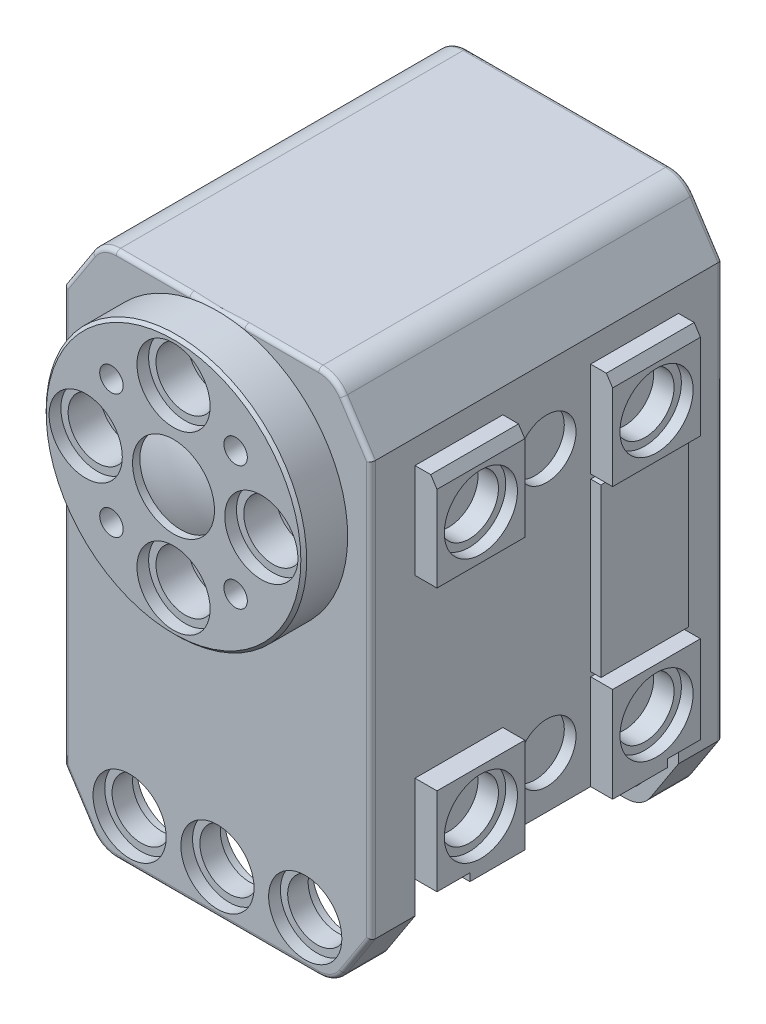
from build123d import *

# Parameters (mm, degrees)
BOSS_EXTRUDE1_DEPTH                                = 3
SKETCH3_W                                          = 1.5
SKETCH3_H                                          = 3
CUT_EXTRUDE1_DEPTH                                 = 1.65033759
BOSS_EXTRUDE2_DEPTH                                = 18
SKETCH5_W                                          = 1.5
SKETCH5_H                                          = 26.65033759
CUT_EXTRUDE2_DEPTH                                 = 3
CUT_EXTRUDE3_DEPTH                                 = 7
SKETCH7_W                                          = 1.5
SKETCH7_H                                          = 26.65033759
CUT_EXTRUDE4_DEPTH                                 = 3
SKETCH8_W                                          = 1.5
SKETCH8_H                                          = 18
CUT_EXTRUDE5_DEPTH                                 = 20.15033759
SKETCH9_W                                          = 1.5
SKETCH9_H                                          = 6.5
CUT_EXTRUDE6_DEPTH                                 = 12
CUT_EXTRUDE7_DEPTH                                 = 2.25
CUT_EXTRUDE8_DEPTH                                 = 2.25
CUT_EXTRUDE9_DEPTH                                 = 2.25
CUT_EXTRUDE10_DEPTH                                = 2.25
SKETCH14_W                                         = 1.5
SKETCH14_H                                         = 12
CUT_EXTRUDE11_DEPTH                                = 20.15033759
SKETCH15_W                                         = 1.5
SKETCH15_H                                         = 6.5
CUT_EXTRUDE12_DEPTH                                = 6
SKETCH16_W                                         = 1.5
SKETCH16_H                                         = 6
CUT_EXTRUDE13_DEPTH                                = 20.15033759
BOSS_EXTRUDE3_DEPTH                                = 1.5
BOSS_EXTRUDE4_DEPTH                                = 3
SKETCH19_R                                         = 2.5
CUT_EXTRUDE14_DEPTH                                = 0.8
SKETCH20_R                                         = 2.5
CUT_EXTRUDE15_DEPTH                                = 0.8
CUT_EXTRUDE16_REACH                                = 25.2
SKETCH21_R                                         = 2
SKETCH22_R                                         = 2.5
CUT_EXTRUDE17_DEPTH                                = 0.8
SKETCH23_R                                         = 2.5
CUT_EXTRUDE18_DEPTH                                = 0.8
CUT_EXTRUDE19_REACH                                = 28.2
SKETCH24_R                                         = 2
SKETCH25_W                                         = 6
SKETCH25_H                                         = 6.5
BOSS_EXTRUDE5_DEPTH                                = 1.5
SKETCH26_W                                         = 6
SKETCH26_H                                         = 6.5
BOSS_EXTRUDE6_DEPTH                                = 1.5
SKETCH27_W                                         = 6
SKETCH27_H                                         = 6.5
BOSS_EXTRUDE7_DEPTH                                = 1.5
SKETCH28_W                                         = 6
SKETCH28_H                                         = 6.5
BOSS_EXTRUDE8_DEPTH                                = 1.5
SKETCH29_W                                         = 6
SKETCH29_H                                         = 11.4
BOSS_EXTRUDE9_DEPTH                                = 0.7
SKETCH30_W                                         = 6
SKETCH30_H                                         = 11.4
BOSS_EXTRUDE10_DEPTH                               = 0.7
F_4_0_4_DIAMETER_HOLE1_D                           = 4
F_4_0_4_DIAMETER_HOLE1_DEPTH                       = 0.8
F_4_0_4_DIAMETER_HOLE2_D                           = 4
F_4_0_4_DIAMETER_HOLE2_DEPTH                       = 0.8
CBORE_FOR_M3_5_HEX_HEAD_MACHINE_SCREW1_D           = 4
CBORE_FOR_M3_5_HEX_HEAD_MACHINE_SCREW1_DEPTH       = 2.2
CBORE_FOR_M3_5_HEX_HEAD_MACHINE_SCREW1_CBORE_D     = 5
CBORE_FOR_M3_5_HEX_HEAD_MACHINE_SCREW1_CBORE_DEPTH = 0.8
CBORE_FOR_M3_5_HEX_HEAD_MACHINE_SCREW2_D           = 4
CBORE_FOR_M3_5_HEX_HEAD_MACHINE_SCREW2_DEPTH       = 2.2
CBORE_FOR_M3_5_HEX_HEAD_MACHINE_SCREW2_CBORE_D     = 5
CBORE_FOR_M3_5_HEX_HEAD_MACHINE_SCREW2_CBORE_DEPTH = 0.8
CBORE_FOR_M3_5_HEX_HEAD_MACHINE_SCREW3_D           = 4
CBORE_FOR_M3_5_HEX_HEAD_MACHINE_SCREW3_DEPTH       = 3
CBORE_FOR_M3_5_HEX_HEAD_MACHINE_SCREW3_CBORE_D     = 5
CBORE_FOR_M3_5_HEX_HEAD_MACHINE_SCREW3_CBORE_DEPTH = 0.8
F_1_6_1_6_DIAMETER_HOLE1_D                         = 1.6
F_1_6_1_6_DIAMETER_HOLE1_DEPTH                     = 3
CBORE_FOR_M3_5_HEX_HEAD_MACHINE_SCREW4_D           = 4
CBORE_FOR_M3_5_HEX_HEAD_MACHINE_SCREW4_DEPTH       = 3
CBORE_FOR_M3_5_HEX_HEAD_MACHINE_SCREW4_CBORE_D     = 5
CBORE_FOR_M3_5_HEX_HEAD_MACHINE_SCREW4_CBORE_DEPTH = 0.8
FILLET1_R                                          = 2
CHAMFER2_SIZE                                      = 0.428258237
CHAMFER2_SIZE2                                     = 0.659459855
CHAMFER2_PART_2_SIZE                               = 0.428258237
CHAMFER2_PART_2_SIZE2                              = 0.659459855
CHAMFER2_PART_3_SIZE                               = 0.428258237
CHAMFER2_PART_3_SIZE2                              = 0.659459855
CHAMFER2_PART_4_SIZE                               = 0.428258237
CHAMFER2_PART_4_SIZE2                              = 0.659459855
CHAMFER4_SIZE                                      = 0.2
FILLET2_R                                          = 0.3


with BuildPart() as part:
    # Sketch1 → Revolve1 (revolve)
    with BuildSketch(Plane(origin=(0, 0, 0), x_dir=(1, 0, 0), z_dir=(0, 1, 0))):
        with BuildLine():
            Line((8.9, -12), (0, -12))
            Line((0, -12), (0, -15))
            ThreePointArc((0, -15), (1.422146265, -14.874019086), (2.8, -14.5))
            Line((2.8, -14.5), (2.8, -15))
            Line((2.8, -15), (8.9, -15))
            Line((8.9, -15), (8.9, -12))
        make_face()
    revolve(axis=Axis((0, 0, 12), (0, 0, 1)))

    # Sketch2 → Boss-Extrude1 (add)
    with BuildSketch(Plane.XY.offset(12)):
        Polygon((12, -23.15033759), (12, 5.15033759), (10.5, 5.15033759), (8, 9), (-8, 9), (-10.5, 5.15033759), (-12, 5.15033759), (-12, -21.5), (-11.571741763, -21.5), (-8, -27), (8, -27), (10.5, -23.15033759), align=None)
    extrude(amount=-BOSS_EXTRUDE1_DEPTH)

    # Sketch3 → Cut-Extrude1 (cut)
    with BuildSketch(Plane.XZ.offset(23.15033759)):
        with Locations((11.25, 10.5)):
            Rectangle(SKETCH3_W, SKETCH3_H)
    extrude(amount=-CUT_EXTRUDE1_DEPTH, mode=Mode.SUBTRACT)

    # Sketch4 → Boss-Extrude2 (add)
    with BuildSketch(Plane(origin=(0, 0, 9), x_dir=(-1, 0, 0), z_dir=(0, 0, -1))):
        with BuildLine():
            Line((-10.5, 5.15033759), (-8, 9))
            Line((-8, 9), (8, 9))
            Line((8, 9), (10.5, 5.15033759))
            Line((10.5, 5.15033759), (12, 5.15033759))
            Line((12, 5.15033759), (12, -21.5))
            Line((12, -21.5), (6, -21.5))
            ThreePointArc((6, -21.5), (4.881966011, -21.763932023), (4, -22.5))
            Line((4, -22.5), (-4, -22.5))
            ThreePointArc((-4, -22.5), (-4.881966011, -21.763932023), (-6, -21.5))
            Line((-6, -21.5), (-12, -21.5))
            Line((-12, -21.5), (-12, 5.15033759))
            Line((-12, 5.15033759), (-10.5, 5.15033759))
        make_face()
    extrude(amount=BOSS_EXTRUDE2_DEPTH)

    # Sketch5 → Cut-Extrude2 (cut)
    with BuildSketch(Plane.XY.offset(12)):
        with Locations((11.25, -8.174831205)):
            Rectangle(SKETCH5_W, SKETCH5_H)
    extrude(amount=-CUT_EXTRUDE2_DEPTH, mode=Mode.SUBTRACT)

    # Sketch6 → Cut-Extrude3 (cut, through all)
    with BuildSketch(Plane(origin=(0, 0, 9), x_dir=(-1, 0, 0), z_dir=(0, 0, -1))):
        Polygon((10.5, -21.5), (10.5, -23.15033759), (11.571741763, -21.5), align=None)
    extrude(amount=-CUT_EXTRUDE3_DEPTH, mode=Mode.SUBTRACT)

    # Sketch7 → Cut-Extrude4 (cut)
    with BuildSketch(Plane.XY.offset(12)):
        with Locations((-11.25, -8.174831205)):
            Rectangle(SKETCH7_W, SKETCH7_H)
    extrude(amount=-CUT_EXTRUDE4_DEPTH, mode=Mode.SUBTRACT)

    # Sketch8 → Cut-Extrude5 (cut)
    with BuildSketch(Plane(origin=(0, 5.15033759, 0), x_dir=(-1, 0, 0), z_dir=(0, 1, 0))):
        with Locations((-11.25, 0)):
            Rectangle(SKETCH8_W, SKETCH8_H)
    extrude(amount=-CUT_EXTRUDE5_DEPTH, mode=Mode.SUBTRACT)

    # Sketch9 → Cut-Extrude6 (cut)
    with BuildSketch(Plane(origin=(0, 0, -9), x_dir=(-1, 0, 0), z_dir=(0, 0, -1))):
        with Locations((-11.25, -18.25)):
            Rectangle(SKETCH9_W, SKETCH9_H)
    extrude(amount=-CUT_EXTRUDE6_DEPTH, mode=Mode.SUBTRACT)

    # Sketch10 → Cut-Extrude7 (cut)
    with BuildSketch(Plane(origin=(0, 0, -9), x_dir=(-1, 0, 0), z_dir=(0, 0, -1))):
        with BuildLine():
            Line((-10.5, -20.975), (-10.5, -21.5))
            Line((-10.5, -21.5), (-6, -21.5))
            ThreePointArc((-6, -21.5), (-4.881966011, -21.763932023), (-4, -22.5))
            Line((-4, -22.5), (-3.373095929, -22.5))
            ThreePointArc((-3.373095929, -22.5), (-4.48126286, -21.383884081), (-6, -20.975))
            Line((-6, -20.975), (-10.5, -20.975))
        make_face()
    extrude(amount=-CUT_EXTRUDE7_DEPTH, mode=Mode.SUBTRACT)

    # Sketch11 → Cut-Extrude8 (cut)
    with BuildSketch(Plane(origin=(0, 0, -9), x_dir=(-1, 0, 0), z_dir=(0, 0, -1))):
        with BuildLine():
            Line((3.373095929, -22.5), (4, -22.5))
            ThreePointArc((4, -22.5), (4.881966011, -21.763932023), (6, -21.5))
            Line((6, -21.5), (12, -21.5))
            Line((12, -21.5), (12, -20.975))
            Line((12, -20.975), (6, -20.975))
            ThreePointArc((6, -20.975), (4.48126286, -21.383884081), (3.373095929, -22.5))
        make_face()
    extrude(amount=-CUT_EXTRUDE8_DEPTH, mode=Mode.SUBTRACT)

    # Sketch12 → Cut-Extrude9 (cut)
    with BuildSketch(Plane.XY.offset(9)):
        with BuildLine():
            Line((3.373095929, -22.5), (4, -22.5))
            ThreePointArc((4, -22.5), (4.881966011, -21.763932023), (6, -21.5))
            Line((6, -21.5), (12, -21.5))
            Line((12, -21.5), (12, -20.975))
            Line((12, -20.975), (6, -20.975))
            ThreePointArc((6, -20.975), (4.48126286, -21.383884081), (3.373095929, -22.5))
        make_face()
    extrude(amount=-CUT_EXTRUDE9_DEPTH, mode=Mode.SUBTRACT)

    # Sketch13 → Cut-Extrude10 (cut)
    with BuildSketch(Plane.XY.offset(9)):
        with BuildLine():
            Line((-6, -20.975), (-12, -20.975))
            Line((-12, -20.975), (-12, -21.5))
            Line((-12, -21.5), (-6, -21.5))
            ThreePointArc((-6, -21.5), (-4.881966011, -21.763932023), (-4, -22.5))
            Line((-4, -22.5), (-3.373095929, -22.5))
            ThreePointArc((-3.373095929, -22.5), (-4.48126286, -21.383884081), (-6, -20.975))
        make_face()
    extrude(amount=-CUT_EXTRUDE10_DEPTH, mode=Mode.SUBTRACT)

    # Sketch14 → Cut-Extrude11 (cut)
    with BuildSketch(Plane(origin=(0, 5.15033759, 0), x_dir=(-1, 0, 0), z_dir=(0, 1, 0))):
        with Locations((11.25, 3)):
            Rectangle(SKETCH14_W, SKETCH14_H)
    extrude(amount=-CUT_EXTRUDE11_DEPTH, mode=Mode.SUBTRACT)

    # Sketch15 → Cut-Extrude12 (cut)
    with BuildSketch(Plane(origin=(0, 0, -3), x_dir=(-1, 0, 0), z_dir=(0, 0, -1))):
        with Locations((11.25, -18.25)):
            Rectangle(SKETCH15_W, SKETCH15_H)
    extrude(amount=-CUT_EXTRUDE12_DEPTH, mode=Mode.SUBTRACT)

    # Sketch16 → Cut-Extrude13 (cut)
    with BuildSketch(Plane(origin=(0, 5.15033759, 0), x_dir=(-1, 0, 0), z_dir=(0, 1, 0))):
        with Locations((11.25, -6)):
            Rectangle(SKETCH16_W, SKETCH16_H)
    extrude(amount=-CUT_EXTRUDE13_DEPTH, mode=Mode.SUBTRACT)

    # Sketch17 → Boss-Extrude3 (add)
    with BuildSketch(Plane(origin=(10.5, 0, 0), x_dir=(0, 0, -1), z_dir=(1, 0, 0))):
        Polygon((3, -21.5), (3, -15), (9, -15), (9, -20.975), (6.75, -20.975), (6.75, -21.5), align=None)
    extrude(amount=BOSS_EXTRUDE3_DEPTH)

    # Sketch18 → Boss-Extrude4 (add)
    with BuildSketch(Plane(origin=(0, 0, -9), x_dir=(-1, 0, 0), z_dir=(0, 0, -1))):
        Polygon((-8, 9), (8, 9), (10.5, 5.15033759), (10.5, -23.15033759), (8, -27), (-8, -27), (-10.5, -23.15033759), (-10.5, 5.15033759), align=None)
    extrude(amount=BOSS_EXTRUDE4_DEPTH)

    # Sketch19 → Cut-Extrude14 (cut)
    with BuildSketch(Plane(origin=(0, 0, 9), x_dir=(-1, 0, 0), z_dir=(0, 0, -1))):
        with Locations((6, -24)):
            Circle(SKETCH19_R)
    extrude(amount=-CUT_EXTRUDE14_DEPTH, mode=Mode.SUBTRACT)

    # Sketch20 → Cut-Extrude15 (cut)
    with BuildSketch(Plane.XY.offset(12)):
        with Locations((-6, -24)):
            Circle(SKETCH20_R)
    extrude(amount=-CUT_EXTRUDE15_DEPTH, mode=Mode.SUBTRACT)

    # Sketch21 → Cut-Extrude16 (cut, up to next)
    with BuildSketch(Plane.XY.offset(11.2), mode=Mode.PRIVATE) as cut_extrude16_sk1:
        with Locations((-6, -24)):
            Circle(SKETCH21_R)
    cut_extrude16_tool1 = extrude(cut_extrude16_sk1.sketch, amount=-CUT_EXTRUDE16_REACH, mode=Mode.PRIVATE) & part.part
    add(cut_extrude16_tool1.solids().sort_by_distance((-6, -24, 11.2))[0], mode=Mode.SUBTRACT)

    # Sketch22 → Cut-Extrude17 (cut)
    with BuildSketch(Plane.XY.offset(-9)):
        with Locations((-6, -24)):
            Circle(SKETCH22_R)
    extrude(amount=-CUT_EXTRUDE17_DEPTH, mode=Mode.SUBTRACT)

    # Sketch23 → Cut-Extrude18 (cut)
    with BuildSketch(Plane(origin=(0, 0, -12), x_dir=(-1, 0, 0), z_dir=(0, 0, -1))):
        with Locations((6, -24)):
            Circle(SKETCH23_R)
    extrude(amount=-CUT_EXTRUDE18_DEPTH, mode=Mode.SUBTRACT)

    # Sketch24 → Cut-Extrude19 (cut, up to next)
    with BuildSketch(Plane(origin=(0, 0, -11.2), x_dir=(-1, 0, 0), z_dir=(0, 0, -1)), mode=Mode.PRIVATE) as cut_extrude19_sk1:
        with Locations((6, -24)):
            Circle(SKETCH24_R)
    cut_extrude19_tool1 = extrude(cut_extrude19_sk1.sketch, amount=-CUT_EXTRUDE19_REACH, mode=Mode.PRIVATE) & part.part
    add(cut_extrude19_tool1.solids().sort_by_distance((-6, -24, -11.2))[0], mode=Mode.SUBTRACT)

    # Sketch25 → Boss-Extrude5 (add)
    with BuildSketch(Plane.ZY.offset(10.5)):
        with Locations((6, 0.25)):
            Rectangle(SKETCH25_W, SKETCH25_H)
    extrude(amount=BOSS_EXTRUDE5_DEPTH)

    # Sketch26 → Boss-Extrude6 (add)
    with BuildSketch(Plane.ZY.offset(10.5)):
        with Locations((-6, 0.25)):
            Rectangle(SKETCH26_W, SKETCH26_H)
    extrude(amount=BOSS_EXTRUDE6_DEPTH)

    # Sketch27 → Boss-Extrude7 (add)
    with BuildSketch(Plane(origin=(10.5, 0, 0), x_dir=(0, 0, -1), z_dir=(1, 0, 0))):
        with Locations((-6, 0.25)):
            Rectangle(SKETCH27_W, SKETCH27_H)
    extrude(amount=BOSS_EXTRUDE7_DEPTH)

    # Sketch28 → Boss-Extrude8 (add)
    with BuildSketch(Plane(origin=(10.5, 0, 0), x_dir=(0, 0, -1), z_dir=(1, 0, 0))):
        with Locations((6, 0.25)):
            Rectangle(SKETCH28_W, SKETCH28_H)
    extrude(amount=BOSS_EXTRUDE8_DEPTH)

    # Sketch29 → Boss-Extrude9 (add)
    with BuildSketch(Plane(origin=(10.5, 0, 0), x_dir=(0, 0, -1), z_dir=(1, 0, 0))):
        with Locations((6, -9)):
            Rectangle(SKETCH29_W, SKETCH29_H)
    extrude(amount=BOSS_EXTRUDE9_DEPTH)

    # Sketch30 → Boss-Extrude10 (add)
    with BuildSketch(Plane.ZY.offset(10.5)):
        with Locations((-6, -9)):
            Rectangle(SKETCH30_W, SKETCH30_H)
    extrude(amount=BOSS_EXTRUDE10_DEPTH)

    # Sketch31 → Cut-Revolve1 (revolve, cut)
    with BuildSketch(Plane(origin=(0, -24, 0), x_dir=(1, 0, 0), z_dir=(0, 1, 0))):
        Polygon((2.5, -9), (0, -9), (0, -12), (2.5, -12), (2.5, -11.2), (2, -11.2), (2, -9.8), (2.5, -9.8), align=None)
    revolve(axis=Axis((0, -24, 9), (0, 0, 1)), mode=Mode.SUBTRACT)

    # Sketch32 → Cut-Revolve2 (revolve, cut)
    with BuildSketch(Plane(origin=(0, -24, 0), x_dir=(1, 0, 0), z_dir=(0, 1, 0))):
        Polygon((2.5, 12), (0, 12), (0, 9), (2.5, 9), (2.5, 9.8), (2, 9.8), (2, 11.2), (2.5, 11.2), align=None)
    revolve(axis=Axis((0, -24, -12), (0, 0, 1)), mode=Mode.SUBTRACT)

    # Sketch33 → Cut-Revolve3 (revolve, cut)
    with BuildSketch(Plane(origin=(0, -24, 0), x_dir=(1, 0, 0), z_dir=(0, 1, 0))):
        Polygon((8.5, 12), (6, 12), (6, 9), (8.5, 9), (8.5, 9.8), (8, 9.8), (8, 11.2), (8.5, 11.2), align=None)
    revolve(axis=Axis((6, -24, -12), (0, 0, 1)), mode=Mode.SUBTRACT)

    # Sketch34 → Cut-Revolve4 (revolve, cut)
    with BuildSketch(Plane(origin=(0, -24, 0), x_dir=(1, 0, 0), z_dir=(0, 1, 0))):
        Polygon((8.5, -9), (6, -9), (6, -12), (8.5, -12), (8.5, -11.2), (8, -11.2), (8, -9.8), (8.5, -9.8), align=None)
    revolve(axis=Axis((6, -24, 9), (0, 0, 1)), mode=Mode.SUBTRACT)

    # Ø4.0 (4) Diameter Hole1
    with Locations(Plane.ZY.offset(10.5)):
        with Locations((0, 0), (0, -18)):
            Hole(F_4_0_4_DIAMETER_HOLE1_D / 2, depth=F_4_0_4_DIAMETER_HOLE1_DEPTH)

    # Ø4.0 (4) Diameter Hole2
    with Locations(Plane(origin=(10.5, 0, 0), x_dir=(0, 0, -1), z_dir=(1, 0, 0))):
        with Locations((0, 0), (0, -18)):
            Hole(F_4_0_4_DIAMETER_HOLE2_D / 2, depth=F_4_0_4_DIAMETER_HOLE2_DEPTH)

    # CBORE for M3.5 Hex Head Machine Screw1
    with Locations(Plane(origin=(12, 0, 0), x_dir=(0, 0, -1), z_dir=(1, 0, 0))):
        with Locations((6, 0), (-6, 0), (6, -18), (-6, -18)):
            CounterBoreHole(CBORE_FOR_M3_5_HEX_HEAD_MACHINE_SCREW1_D / 2, CBORE_FOR_M3_5_HEX_HEAD_MACHINE_SCREW1_CBORE_D / 2, CBORE_FOR_M3_5_HEX_HEAD_MACHINE_SCREW1_CBORE_DEPTH, depth=CBORE_FOR_M3_5_HEX_HEAD_MACHINE_SCREW1_DEPTH)

    # CBORE for M3.5 Hex Head Machine Screw2
    with Locations(Plane.ZY.offset(12)):
        with Locations((-6, 0), (6, 0), (-6, -18), (6, -18)):
            CounterBoreHole(CBORE_FOR_M3_5_HEX_HEAD_MACHINE_SCREW2_D / 2, CBORE_FOR_M3_5_HEX_HEAD_MACHINE_SCREW2_CBORE_D / 2, CBORE_FOR_M3_5_HEX_HEAD_MACHINE_SCREW2_CBORE_DEPTH, depth=CBORE_FOR_M3_5_HEX_HEAD_MACHINE_SCREW2_DEPTH)

    # CBORE for M3.5 Hex Head Machine Screw3
    with Locations(Plane(origin=(0, 0, -12), x_dir=(-1, 0, 0), z_dir=(0, 0, -1))):
        with Locations((6, 0), (0, 0), (-6, 0)):
            CounterBoreHole(CBORE_FOR_M3_5_HEX_HEAD_MACHINE_SCREW3_D / 2, CBORE_FOR_M3_5_HEX_HEAD_MACHINE_SCREW3_CBORE_D / 2, CBORE_FOR_M3_5_HEX_HEAD_MACHINE_SCREW3_CBORE_DEPTH, depth=CBORE_FOR_M3_5_HEX_HEAD_MACHINE_SCREW3_DEPTH)

    # Ø1.6 (1.6) Diameter Hole1
    with Locations(Plane.XY.offset(15)):
        with Locations((4.242640687, 4.242640687), (-4.242640687, 4.242640687), (4.242640687, -4.242640687), (-4.242640687, -4.242640687)):
            Hole(F_1_6_1_6_DIAMETER_HOLE1_D / 2, depth=F_1_6_1_6_DIAMETER_HOLE1_DEPTH)

    # CBORE for M3.5 Hex Head Machine Screw4
    with Locations(Plane.XY.offset(15)):
        with Locations((6, 0), (0, 6), (-6, 0), (0, -6)):
            CounterBoreHole(CBORE_FOR_M3_5_HEX_HEAD_MACHINE_SCREW4_D / 2, CBORE_FOR_M3_5_HEX_HEAD_MACHINE_SCREW4_CBORE_D / 2, CBORE_FOR_M3_5_HEX_HEAD_MACHINE_SCREW4_CBORE_DEPTH, depth=CBORE_FOR_M3_5_HEX_HEAD_MACHINE_SCREW4_DEPTH)

    # Fillet1
    fillet1_edges = [part.edges().sort_by_distance(p)[0] for p in [
        (8, -27, 10.5),
        (-8, -27, 10.5),
        (-8, 9, 0),
        (8, 9, 0),
        (8, -27, -10.5),
        (-8, -27, -10.5),
    ]]
    fillet(fillet1_edges, radius=FILLET1_R)

    # Chamfer2
    chamfer2_edges = [part.edges().sort_by_distance(p)[0] for p in [
        (-12, 3.5, 6),
    ]]
    chamfer2_side = [part.faces().sort_by_distance(p)[0] for p in [
        (-11.25, 3.5, 6),
    ]]
    chamfer(chamfer2_edges, length=CHAMFER2_SIZE, length2=CHAMFER2_SIZE2, reference=chamfer2_side[0])

    # Chamfer2 part 2
    chamfer2_part_2_edges = [part.edges().sort_by_distance(p)[0] for p in [
        (-12, 3.5, -6),
    ]]
    chamfer2_part_2_side = [part.faces().sort_by_distance(p)[0] for p in [
        (-11.25, 3.5, -6),
    ]]
    chamfer(chamfer2_part_2_edges, length=CHAMFER2_PART_2_SIZE, length2=CHAMFER2_PART_2_SIZE2, reference=chamfer2_part_2_side[0])

    # Chamfer2 part 3
    chamfer2_part_3_edges = [part.edges().sort_by_distance(p)[0] for p in [
        (12, 3.5, 6),
    ]]
    chamfer2_part_3_side = [part.faces().sort_by_distance(p)[0] for p in [
        (11.25, 3.5, 6),
    ]]
    chamfer(chamfer2_part_3_edges, length=CHAMFER2_PART_3_SIZE, length2=CHAMFER2_PART_3_SIZE2, reference=chamfer2_part_3_side[0])

    # Chamfer2 part 4
    chamfer2_part_4_edges = [part.edges().sort_by_distance(p)[0] for p in [
        (12, 3.5, -6),
    ]]
    chamfer2_part_4_side = [part.faces().sort_by_distance(p)[0] for p in [
        (11.25, 3.5, -6),
    ]]
    chamfer(chamfer2_part_4_edges, length=CHAMFER2_PART_4_SIZE, length2=CHAMFER2_PART_4_SIZE2, reference=chamfer2_part_4_side[0])

    # Chamfer4
    chamfer4_edges = [part.edges().sort_by_distance(p)[0] for p in [
        (-8.9, 0, 15),
    ]]
    chamfer(chamfer4_edges, length=CHAMFER4_SIZE)

    # Fillet2
    fillet2_edges = [part.edges().sort_by_distance(p)[0] for p in [
        (-9.545714868, -24.61980783, 12),
        (-10.5, -9, 12),
        (9.545714868, 6.61980783, 12),
        (10.5, -9, -12),
        (9.545714868, -24.61980783, -12),
        (-10.5, -9, -12),
        (-9.545714868, 6.61980783, -12),
        (10.5, -9, 12),
        (-9.545714868, -24.61980783, -12),
        (0, -27, -12),
        (9.545714868, 6.61980783, -12),
        (0, 9, -12),
        (7.868406121, -26.757634225, -12),
        (-7.868406121, 8.757634225, -12),
        (7.868406121, 8.757634225, -12),
        (-7.868406121, -26.757634225, -12),
        (0, -27, 12),
        (-9.545714868, 6.61980783, 12),
        (9.545714868, -24.61980783, 12),
        (0, 9, 12),
        (-7.868406121, -26.757634225, 12),
        (-7.868406121, 8.757634225, 12),
        (7.868406121, 8.757634225, 12),
        (7.868406121, -26.757634225, 12),
    ]]
    fillet(fillet2_edges, radius=FILLET2_R)


solid = part.part
